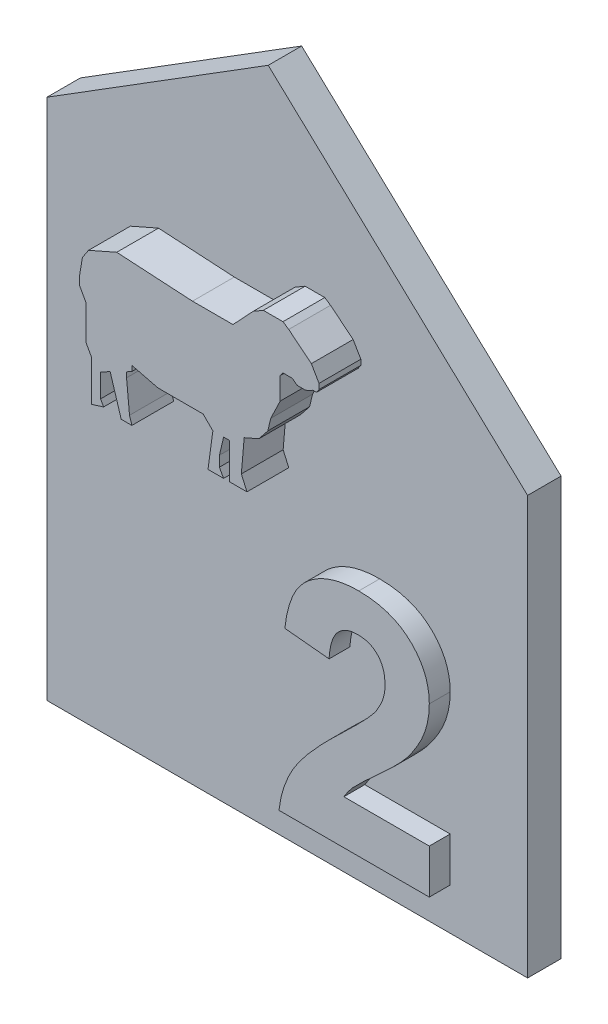
from build123d import *

# Parameters (mm, degrees)
P_IDAT_VYSUNUT_M5_DEPTH = 1.6
P_IDAT_VYSUNUT_M6_DEPTH = 1
SKETCH1_W               = 14
SKETCH1_H               = 8.811343348
BOSS_EXTRUDE1_DEPTH     = 2
SKETCH2_W               = 14
SKETCH2_H               = 8.811343348
CUT_EXTRUDE1_DEPTH      = 2


with BuildPart() as part:
    # Skica1 → Přidat vysunutím5 (new body)
    with BuildSketch(Plane.XY):
        Polygon((0, 0), (0, 20), (-12.412784718, 31.615626352), (-23, 25), (-23, 0), align=None)
    extrude(amount=P_IDAT_VYSUNUT_M5_DEPTH)

    # Skica2 → Přidat vysunutím6 (add)
    with BuildSketch(Plane.XY.offset(1.6)):
        with BuildLine():
            Line((-3.705128205, 4.115384615), (-3.705128205, 2))
            Line((-3.705128205, 2), (-10.897435897, 2))
            add(Edge.make_bspline(
                [(-10.897435897, 2), (-10.87308441, 2.180790308), (-10.824395089, 2.542269551), (-10.673865117, 3.070299742), (-10.472959166, 3.585566992), (-10.254913916, 4.004869463), (-10.038043764, 4.342393523), (-9.841277463, 4.618963346), (-9.60654249, 4.913221767), (-9.337245105, 5.227544267), (-9.034873554, 5.562913411), (-8.697171951, 5.918082368), (-8.322529407, 6.291350846), (-8.058961705, 6.54481851), (-7.922676282, 6.67588141)],
                knots=[0, 0, 0, 0, 0.000546661, 0.001093015, 0.001642153, 0.002203944, 0.002507135, 0.00284526, 0.003221747, 0.003635945, 0.00408685, 0.004576261, 0.005106025, 0.00567326, 0.00567326, 0.00567326, 0.00567326], degree=3))
            add(Edge.make_bspline(
                [(-7.922676282, 6.67588141), (-7.813918956, 6.780862005), (-7.606877039, 6.980714138), (-7.312048947, 7.266894293), (-7.052864674, 7.529975199), (-6.823905036, 7.763139303), (-6.630459323, 7.972323552), (-6.469982936, 8.154242742), (-6.34044346, 8.309637702), (-6.270284768, 8.408220362), (-6.239182692, 8.451923077)],
                knots=[0, 0, 0, 0, 0.000453482, 0.000863296, 0.001232576, 0.001561374, 0.001843606, 0.002087173, 0.00228919, 0.002450062, 0.002450062, 0.002450062, 0.002450062], degree=3))
            add(Edge.make_bspline(
                [(-6.239182692, 8.451923077), (-6.175493233, 8.557718073), (-6.052643645, 8.761784362), (-5.91792888, 9.082682292), (-5.837068057, 9.403513936), (-5.825971765, 9.617891805), (-5.820512821, 9.723357372)],
                knots=[0, 0, 0, 0, 0.000370068, 0.000713818, 0.001040364, 0.001356575, 0.001356575, 0.001356575, 0.001356575], degree=3))
            add(Edge.make_bspline(
                [(-5.820512821, 9.723357372), (-5.824474653, 9.833108474), (-5.831970132, 10.040748999), (-5.894821019, 10.333768175), (-6.006276867, 10.585659667), (-6.15973106, 10.797196661), (-6.353774193, 10.962935085), (-6.580616259, 11.085399693), (-6.843577862, 11.153106661), (-7.028402789, 11.16201224), (-7.125, 11.166666667)],
                knots=[0, 0, 0, 0, 0.000329064, 0.000622563, 0.000892834, 0.001149779, 0.00139978, 0.001652148, 0.001916728, 0.002206405, 0.002206405, 0.002206405, 0.002206405], degree=3))
            add(Edge.make_bspline(
                [(-7.125, 11.166666667), (-7.220944609, 11.16231978), (-7.406288878, 11.153922533), (-7.669703299, 11.080565334), (-7.900142302, 10.953576306), (-8.06436539, 10.808860058), (-8.175305876, 10.668134018), (-8.250896853, 10.545500545), (-8.316050374, 10.406151312), (-8.37378183, 10.251655158), (-8.419383153, 10.080242168), (-8.456107626, 9.893217825), (-8.485702239, 9.689575671), (-8.495113848, 9.547907653), (-8.5, 9.474358974)],
                knots=[0, 0, 0, 0, 0.000287482, 0.000555353, 0.000811759, 0.001070877, 0.001205779, 0.00134826, 0.001502018, 0.001666561, 0.00184243, 0.002033439, 0.002238177, 0.002459233, 0.002459233, 0.002459233, 0.002459233], degree=3))
            Line((-8.5, 9.474358974), (-10.615384615, 9.681490385))
            add(Edge.make_bspline(
                [(-10.615384615, 9.681490385), (-10.598377251, 9.824305509), (-10.565402688, 10.101201217), (-10.483114114, 10.498918926), (-10.378898684, 10.865831465), (-10.247788098, 11.201257911), (-10.095201314, 11.507331251), (-9.913355139, 11.779458664), (-9.708603468, 12.020654551), (-9.480769352, 12.230790543), (-9.231301205, 12.410535137), (-8.969529148, 12.57098477), (-8.690337423, 12.702604473), (-8.396799939, 12.811078884), (-8.089049352, 12.897770766), (-7.765662274, 12.955090263), (-7.42863453, 12.995409017), (-7.198577984, 12.998446608), (-7.080929487, 13)],
                knots=[0, 0, 0, 0, 0.000431306, 0.000836233, 0.001217004, 0.001574233, 0.001915203, 0.002240945, 0.002553567, 0.002862328, 0.003168197, 0.003474678, 0.003782194, 0.004092453, 0.004412693, 0.004739863, 0.005076887, 0.005429623, 0.005429623, 0.005429623, 0.005429623], degree=3))
            add(Edge.make_bspline(
                [(-7.080929487, 13), (-6.953030371, 12.997541845), (-6.703930784, 12.992754281), (-6.34028961, 12.953218534), (-5.998674853, 12.884282231), (-5.676099879, 12.79296634), (-5.375877361, 12.67105295), (-5.095505554, 12.52366473), (-4.83939702, 12.345207999), (-4.603734114, 12.145414763), (-4.393070332, 11.925706984), (-4.20854792, 11.691351493), (-4.053955652, 11.442511564), (-3.924228998, 11.182220281), (-3.827907833, 10.90628918), (-3.757724044, 10.618533633), (-3.711189366, 10.317611197), (-3.707170936, 10.112088), (-3.705128205, 10.007612179)],
                knots=[0, 0, 0, 0, 0.000383641, 0.00074719, 0.0010955, 0.001428145, 0.001751403, 0.002065859, 0.002376361, 0.002685876, 0.002991333, 0.003287991, 0.003579024, 0.003868752, 0.004158681, 0.00445369, 0.004756592, 0.005069772, 0.005069772, 0.005069772, 0.005069772], degree=3))
            add(Edge.make_bspline(
                [(-3.705128205, 10.007612179), (-3.707819477, 9.887707131), (-3.713158546, 9.649833916), (-3.764276175, 9.298186238), (-3.84237396, 8.954647512), (-3.957796338, 8.618378159), (-4.104103161, 8.28131186), (-4.292696164, 7.942692037), (-4.511666905, 7.592306518), (-4.683112364, 7.36576699), (-4.771634615, 7.248798077)],
                knots=[0, 0, 0, 0, 0.000359506, 0.000713204, 0.001063842, 0.00141504, 0.001778167, 0.002164709, 0.002576738, 0.003016589, 0.003016589, 0.003016589, 0.003016589], degree=3))
            add(Edge.make_bspline(
                [(-4.771634615, 7.248798077), (-4.80509214, 7.206658226), (-4.876750403, 7.116404431), (-4.998659939, 6.978014195), (-5.139942605, 6.826848432), (-5.298602846, 6.660077667), (-5.479881522, 6.483607708), (-5.677256214, 6.290058721), (-5.899411985, 6.089331377), (-6.12951153, 5.876418507), (-6.360611244, 5.669193404), (-6.5730252, 5.472375498), (-6.765967752, 5.298233923), (-6.930453202, 5.137155265), (-7.076156545, 5.000133027), (-7.197826149, 4.880140867), (-7.29773874, 4.780083699), (-7.43541186, 4.624119958), (-7.610585282, 4.413178934), (-7.733826947, 4.21161882), (-7.792668269, 4.115384615)],
                knots=[0, 0, 0, 0, 0.0001614, 0.000345681, 0.000553058, 0.000782151, 0.00103613, 0.001311959, 0.001611379, 0.001934216, 0.002252456, 0.002542536, 0.002802971, 0.003032064, 0.003233117, 0.00340296, 0.003544758, 0.003657116, 0.004027059, 0.004365069, 0.004365069, 0.004365069, 0.004365069], degree=3))
            Line((-7.792668269, 4.115384615), (-3.705128205, 4.115384615))
        make_face()
    extrude(amount=P_IDAT_VYSUNUT_M6_DEPTH)

    # Sketch1 → Boss-Extrude1 (add)
    with BuildSketch(Plane.XY.offset(1.6)):
        with Locations((-14, 19.405671674)):
            Rectangle(SKETCH1_W, SKETCH1_H)
    extrude(amount=BOSS_EXTRUDE1_DEPTH)

    # Sketch2 → Cut-Extrude1 (cut)
    with BuildSketch(Plane.XY.offset(3.6)):
        with Locations((-14, 19.405671674)):
            Rectangle(SKETCH2_W, SKETCH2_H)
        Polygon((-19.444720722, 20.35888782), (-19.444720722, 19.986569127), (-19.131189191, 19.418293227), (-19.131189191, 18.066188499), (-19.131189191, 17.772252689), (-18.858242416, 17.277536659), (-18.858242416, 15.342383323), (-18.288573201, 15.518744809), (-18.433763737, 15.781902655), (-18.433763737, 16.890445258), (-17.976410423, 17.14277812), (-17.446333305, 15.430564066), (-16.936468473, 15.430564066), (-17.049096134, 15.794365214), (-17.191400889, 17.277536659), (-17.191400889, 17.524894674), (-16.936468473, 17.665547041), (-16.936468473, 17.919220594), (-16.426979735, 17.792383818), (-15.689001428, 17.608664763), (-13.526813072, 17.608664763), (-13.06092643, 17.14277812), (-13.293869751, 15.430564066), (-12.547027038, 15.430564066), (-12.747744912, 15.794365214), (-12.747744912, 16.286671093), (-12.547027038, 17.14277812), (-12.253091227, 17.14277812), (-12.253091227, 15.430564066), (-11.430070958, 15.430564066), (-11.697847079, 16.040518153), (-11.563959019, 17.608664763), (-10.856559128, 17.919220594), (-10.430689203, 18.458102913), (-10.293165377, 19.044673063), (-10.019179068, 19.614250434), (-9.840080969, 19.986569127), (-9.840080969, 20.574440748), (-9.840080969, 21.044738045), (-9.705647537, 21.221099531), (-9.431307447, 21.221099531), (-9.254945961, 21.221099531), (-9.023579601, 21.044738045), (-8.627882899, 21.044738045), (-8.427020311, 21.132918788), (-8.275159926, 21.221099531), (-8.09879844, 21.221099531), (-7.981224116, 21.397461017), (-7.981224116, 21.652205386), (-8.348696256, 22.285047188), (-9.431307447, 23.161851588), (-9.705647537, 23.344744981), (-10.64624213, 23.344744981), (-11.128859966, 23.064503366), (-11.697847079, 22.457055221), (-12.098019445, 22.02983296), (-12.547027038, 22.02983296), (-14.03630181, 22.02983296), (-17.661510139, 22.24344409), (-18.61604593, 21.824393055), (-19.008263773, 21.652205386), (-19.30233871, 21.21109298), align=None, mode=Mode.SUBTRACT)
    extrude(amount=-CUT_EXTRUDE1_DEPTH, mode=Mode.SUBTRACT)


solid = part.part
